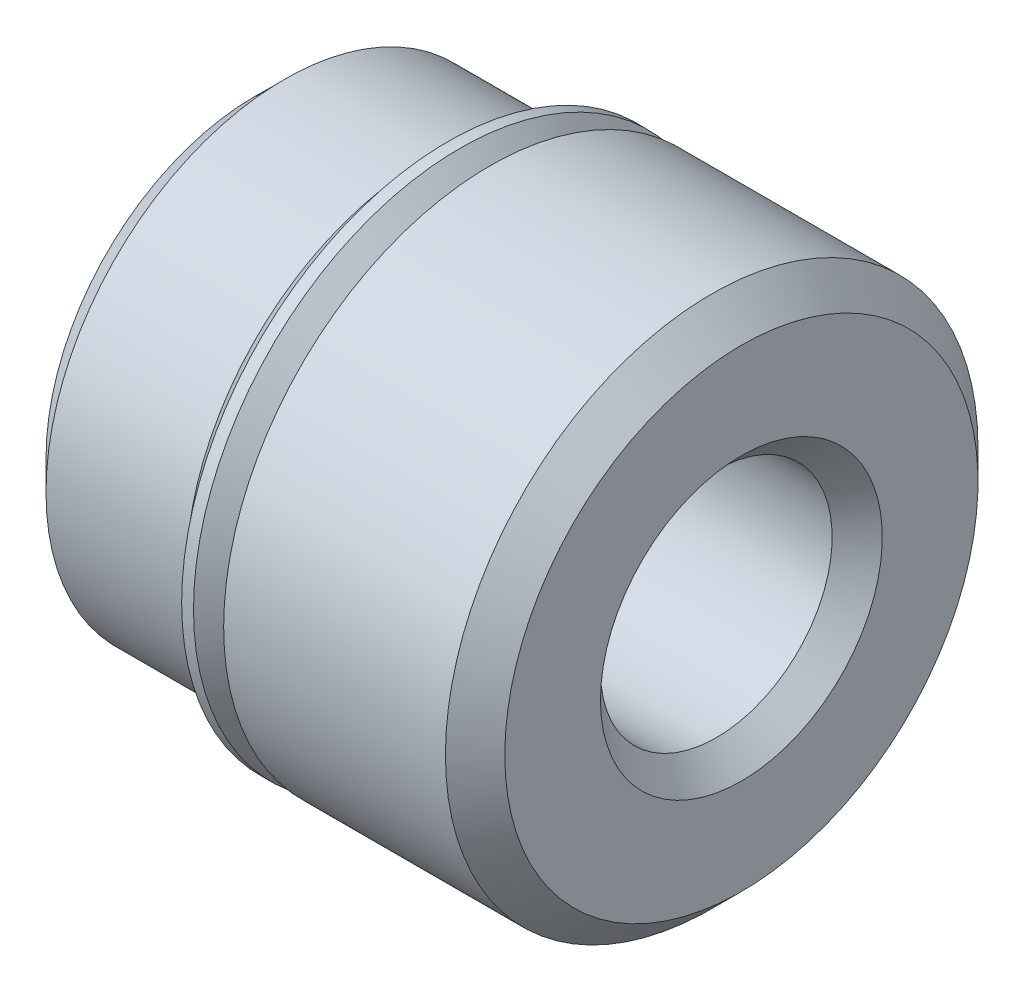
from build123d import *


with BuildPart() as part:
    # Sketch1 → Revolve1 (revolve)
    with BuildSketch(Plane.XY):
        Polygon((0, 0), (0, 3.57505), (0.508, 4.08305), (2.9083, 4.08305), (3.4671, 3.52425), (4.0259, 3.52425), (4.0259, 4.5593), (7.8232, 4.5593), (8.3312, 4.0513), (8.3312, 0), align=None)
    revolve(axis=Axis((8.3312, 0, 0), (-1, 0, 0)))

    # Sketch2 → Cut-Revolve1 (revolve, cut)
    with BuildSketch(Plane.XY):
        Polygon((0, 0), (0, 2.413), (0.42926, 1.98374), (7.90194, 1.98374), (8.3312, 2.413), (8.3312, 0), align=None)
    revolve(axis=Axis((8.3312, 0, 0), (-1, 0, 0)), mode=Mode.SUBTRACT)

    # Sketch3 → Revolve2 (revolve)
    with BuildSketch(Plane.XY):
        with BuildLine():
            Line((3.306480735, 4.475131804), (3.912128708, 3.869483831))
            ThreePointArc((3.912128708, 3.869483831), (3.949326147, 3.779681269), (3.912128708, 3.689878708))
            Line((3.912128708, 3.689878708), (3.7465, 3.52425))
            Line((3.7465, 3.52425), (3.4671, 3.52425))
            Line((3.4671, 3.52425), (3.4671, 3.27025))
            Line((3.4671, 3.27025), (4.0259, 3.27025))
            Line((4.0259, 3.27025), (4.0259, 4.043080735))
            Line((4.0259, 4.043080735), (3.509680735, 4.5593))
            Line((3.509680735, 4.5593), (3.306480735, 4.5593))
            Line((3.306480735, 4.5593), (3.306480735, 4.475131804))
        make_face()
    revolve(axis=Axis((4.0259, 0, 0), (-1, 0, 0)))


solid = part.part
